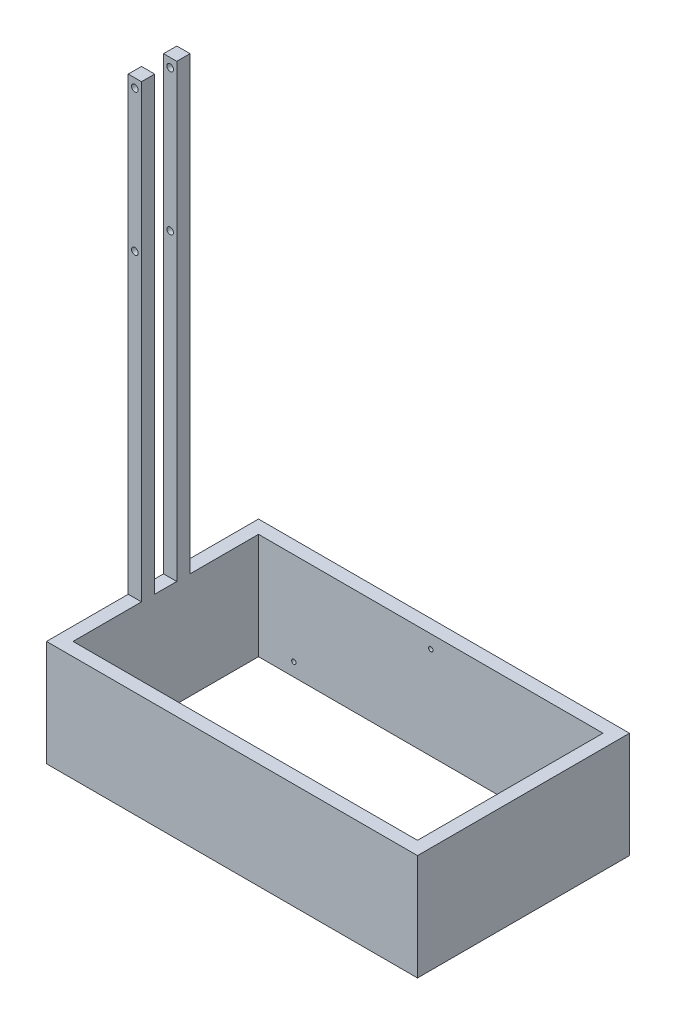
from build123d import *

# Parameters (mm, degrees)
SKETCH1_W           = 2133.6
SKETCH1_H           = 1219.2
BOSS_EXTRUDE1_DEPTH = 609.6
SKETCH2_W           = 1981.2
SKETCH2_H           = 1066.8
CUT_EXTRUDE1_DEPTH  = 609.6
SKETCH5_R           = 12.7
CUT_EXTRUDE2_DEPTH  = 50.8
SKETCH6_R           = 12.7
CUT_EXTRUDE3_DEPTH  = 50.8
SKETCH7_R           = 12.7
BOSS_EXTRUDE2_DEPTH = 50.8
SKETCH8_R           = 12.7
CUT_EXTRUDE4_DEPTH  = 50.8
SKETCH10_R          = 12.7
CUT_EXTRUDE5_DEPTH  = 50.8
SKETCH11_W          = 76.2
SKETCH11_H          = 76.2
BOSS_EXTRUDE3_DEPTH = 2590.8
SKETCH12_R          = 19.05
CUT_EXTRUDE6_DEPTH  = 2590.8
SKETCH13_R          = 19.05
CUT_EXTRUDE7_DEPTH  = 1524


with BuildPart() as part:
    # Sketch1 → Boss-Extrude1 (new body)
    with BuildSketch(Plane(origin=(0, 0, 0), x_dir=(1, 0, 0), z_dir=(0, 1, 0))):
        with Locations((1066.8, 609.6)):
            Rectangle(SKETCH1_W, SKETCH1_H)
    extrude(amount=BOSS_EXTRUDE1_DEPTH)

    # Sketch2 → Cut-Extrude1 (cut)
    with BuildSketch(Plane(origin=(0, 609.6, 0), x_dir=(1, 0, 0), z_dir=(0, 1, 0))):
        with Locations((1066.8, 609.6)):
            Rectangle(SKETCH2_W, SKETCH2_H)
    extrude(amount=-CUT_EXTRUDE1_DEPTH, mode=Mode.SUBTRACT)

    # Sketch5 → Cut-Extrude2 (cut)
    with BuildSketch(Plane(origin=(0, 0, -76.2), x_dir=(-1, 0, 0), z_dir=(0, 0, -1))):
        with Locations((-279.4, 76.2)):
            Circle(SKETCH5_R)
        with Locations((-1854.2, 76.2)):
            Circle(SKETCH5_R)
    extrude(amount=-CUT_EXTRUDE2_DEPTH, mode=Mode.SUBTRACT)

    # Sketch6 → Cut-Extrude3 (cut)
    with BuildSketch(Plane.XY.offset(-1143)):
        with Locations((1854.2, 76.2)):
            Circle(SKETCH6_R)
        with Locations((279.4, 76.2)):
            Circle(SKETCH6_R)
    extrude(amount=-CUT_EXTRUDE3_DEPTH, mode=Mode.SUBTRACT)

    # Sketch7 → Boss-Extrude2 (add)
    with BuildSketch(Plane.XY.offset(-1143)):
        with Locations((1066.8, 508)):
            Circle(SKETCH7_R)
    extrude(amount=-BOSS_EXTRUDE2_DEPTH)

    # Sketch8 → Cut-Extrude4 (cut)
    with BuildSketch(Plane(origin=(0, 0, -76.2), x_dir=(-1, 0, 0), z_dir=(0, 0, -1))):
        with Locations((-1066.8, 533.4)):
            Circle(SKETCH8_R)
    extrude(amount=-CUT_EXTRUDE4_DEPTH, mode=Mode.SUBTRACT)

    # Sketch10 → Cut-Extrude5 (cut)
    with BuildSketch(Plane.XY.offset(-1143)):
        with Locations((1066.8, 533.4)):
            Circle(SKETCH10_R)
    extrude(amount=-CUT_EXTRUDE5_DEPTH, mode=Mode.SUBTRACT)

    # Sketch11 → Boss-Extrude3 (add)
    with BuildSketch(Plane(origin=(0, 609.6, 0), x_dir=(1, 0, 0), z_dir=(0, 1, 0))):
        with Locations((38.1, 711.2)):
            Rectangle(SKETCH11_W, SKETCH11_H)
        with Locations((38.1, 508)):
            Rectangle(SKETCH11_W, SKETCH11_H)
    extrude(amount=BOSS_EXTRUDE3_DEPTH)

    # Sketch12 → Cut-Extrude6 (cut)
    with BuildSketch(Plane.XY.offset(-469.9)):
        with Locations((38.1, 2336.8)):
            Circle(SKETCH12_R)
    extrude(amount=-CUT_EXTRUDE6_DEPTH, mode=Mode.SUBTRACT)

    # Sketch13 → Cut-Extrude7 (cut)
    with BuildSketch(Plane(origin=(0, 0, -749.3), x_dir=(-1, 0, 0), z_dir=(0, 0, -1))):
        with Locations((-38.1, 3149.6)):
            Circle(SKETCH13_R)
    extrude(amount=-CUT_EXTRUDE7_DEPTH, mode=Mode.SUBTRACT)


solid = part.part
